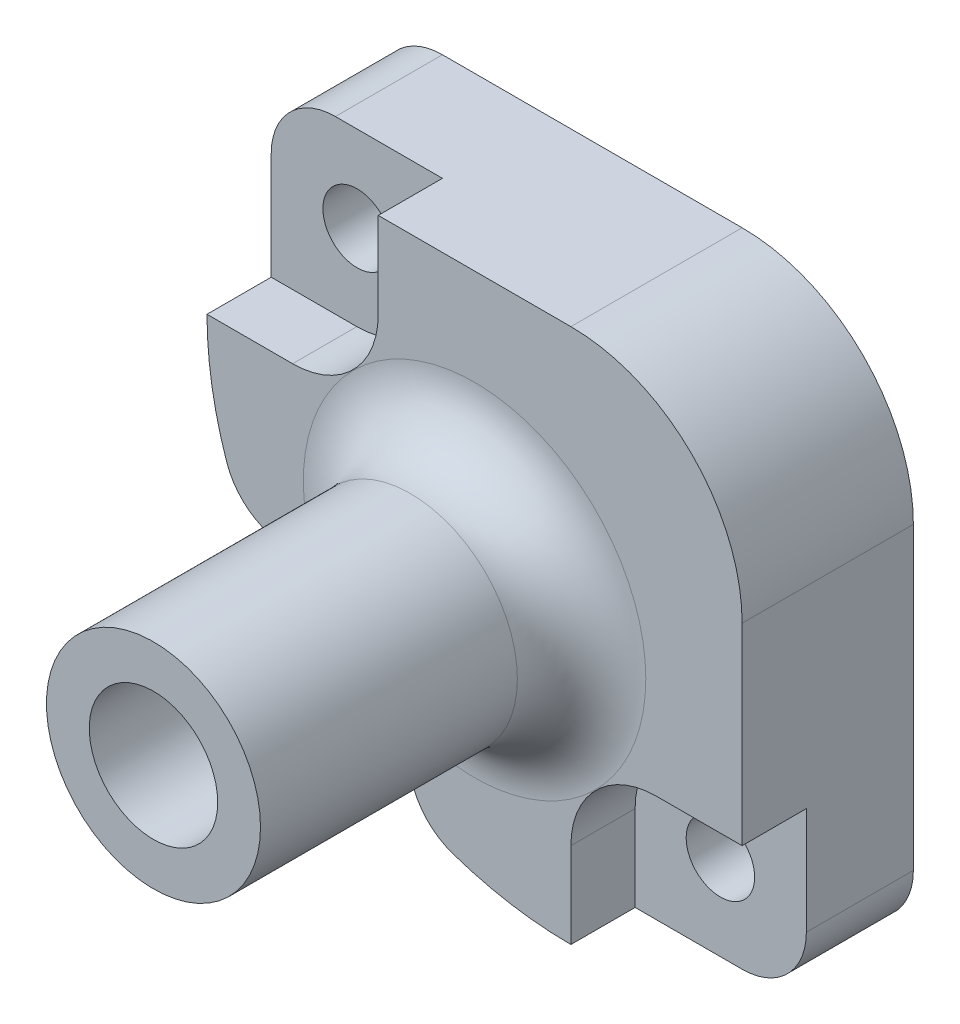
from build123d import *

# Parameters (mm, degrees)
SCHIZZO1_W                           = 25
SCHIZZO1_H                           = 25
ESTRUSIONE_ESTRUSIONE1_DEPTH         = 8
SCHIZZO8_R                           = 5
ESTRUSIONE_ESTRUSIONE3_DEPTH         = 15
RACCORDO1_R                          = 3
TAGLIO_ESTRUSIONE2_REACH             = 25
SCHIZZO9_R                           = 1.6
SCHIZZO10_R                          = 3
TAGLIO_ESTRUSIONE3_DEPTH             = 4
SCHIZZO11_R                          = 3
TAGLIO_ESTRUSIONE4_DEPTH             = 16
TAGLIO_ESTRUSIONE6_REACH             = 25
SCHIZZO13_R                          = 1.6
TAGLIO_ESTRUSIONE8_START             = -3
TAGLIO_ESTRUSIONE8_DEPTH             = 19
RIPETIZIONECIRCOLARE1_COUNT          = 2
RIPETIZIONECIRCOLARE1_ANGLE          = 180
TAGLIO_ESTRUSIONE9_REACH             = 10
TAGLIO_ESTRUSIONE9_DIRECTION_2_REACH = 17
RACCORDO2_R                          = 3
RACCORDO3_R                          = 3
RACCORDO4_R                          = 8


with BuildPart() as part:
    # Schizzo1 → Estrusione-Estrusione1 (new body)
    with BuildSketch(Plane.XY):
        Rectangle(SCHIZZO1_W, SCHIZZO1_H)
    extrude(amount=ESTRUSIONE_ESTRUSIONE1_DEPTH)

    # Schizzo8 → Estrusione-Estrusione3 (add)
    with BuildSketch(Plane.XY.offset(8)):
        Circle(SCHIZZO8_R)
    extrude(amount=ESTRUSIONE_ESTRUSIONE3_DEPTH)

    # Raccordo1
    raccordo1_edges = [part.edges().sort_by_distance(p)[0] for p in [
        (-5, 0, 8),
    ]]
    fillet(raccordo1_edges, radius=RACCORDO1_R)

    # Schizzo9 → Taglio-Estrusione2 (cut, up to next)
    with BuildSketch(Plane(origin=(0, 0, 0), x_dir=(-1, 0, 0), z_dir=(0, 0, -1)), mode=Mode.PRIVATE) as taglio_estrusione2_sk1:
        Circle(SCHIZZO9_R)
    taglio_estrusione2_tool1 = extrude(taglio_estrusione2_sk1.sketch, amount=-TAGLIO_ESTRUSIONE2_REACH, mode=Mode.PRIVATE) & part.part
    add(taglio_estrusione2_tool1.solids().sort_by_distance((0, 0, 0))[0], mode=Mode.SUBTRACT)

    # Schizzo10 → Taglio-Estrusione3 (cut)
    with BuildSketch(Plane(origin=(0, 0, 0), x_dir=(-1, 0, 0), z_dir=(0, 0, -1))):
        Circle(SCHIZZO10_R)
    extrude(amount=-TAGLIO_ESTRUSIONE3_DEPTH, mode=Mode.SUBTRACT)

    # Schizzo11 → Taglio-Estrusione4 (cut)
    with BuildSketch(Plane.XY.offset(23)):
        Circle(SCHIZZO11_R)
    extrude(amount=-TAGLIO_ESTRUSIONE4_DEPTH, mode=Mode.SUBTRACT)

    # Schizzo13 → Taglio-Estrusione6 (cut, up to next)
    with BuildSketch(Plane(origin=(0, 0, 0), x_dir=(-1, 0, 0), z_dir=(0, 0, -1)), mode=Mode.PRIVATE) as taglio_estrusione6_sk1:
        with Locations((-8.485281374, -8.485281374)):
            Circle(SCHIZZO13_R)
    taglio_estrusione6_tool1 = extrude(taglio_estrusione6_sk1.sketch, amount=-TAGLIO_ESTRUSIONE6_REACH, mode=Mode.PRIVATE) & part.part
    add(taglio_estrusione6_tool1.solids().sort_by_distance((8.485281, -8.485281, 0))[0], mode=Mode.SUBTRACT)
    # Schizzo13 → Taglio-Estrusione6 (cut, up to next)
    with BuildSketch(Plane(origin=(0, 0, 0), x_dir=(-1, 0, 0), z_dir=(0, 0, -1)), mode=Mode.PRIVATE) as taglio_estrusione6_sk2:
        with Locations((8.485281374, 8.485281374)):
            Circle(SCHIZZO13_R)
    taglio_estrusione6_tool2 = extrude(taglio_estrusione6_sk2.sketch, amount=-TAGLIO_ESTRUSIONE6_REACH, mode=Mode.PRIVATE) & part.part
    add(taglio_estrusione6_tool2.solids().sort_by_distance((-8.485281, 8.485281, 0))[0], mode=Mode.SUBTRACT)

    # Schizzo17 → Taglio-Estrusione8 (cut)
    with BuildSketch(Plane.XY.offset(8).offset(TAGLIO_ESTRUSIONE8_START)):
        with BuildLine():
            Line((4.5, -12.5), (4.5, -8.5))
            ThreePointArc((4.5, -8.5), (5.671572875, -5.671572875), (8.5, -4.5))
            Line((8.5, -4.5), (12.5, -4.5))
            Line((12.5, -4.5), (12.5, -12.5))
            Line((12.5, -12.5), (4.5, -12.5))
        make_face()
    taglio_estrusione8 = extrude(amount=TAGLIO_ESTRUSIONE8_DEPTH, mode=Mode.SUBTRACT)

    # RipetizioneCircolare1: Taglio-Estrusione8 ×2 about axis
    ripetizionecircolare1_axis = Axis((0, 0, 0), (0, 0, 1))
    for i in range(1, RIPETIZIONECIRCOLARE1_COUNT):
        add(taglio_estrusione8.rotate(ripetizionecircolare1_axis, i * RIPETIZIONECIRCOLARE1_ANGLE / (RIPETIZIONECIRCOLARE1_COUNT - 1)), mode=Mode.SUBTRACT)

    # Schizzo20 → Taglio-Estrusione9 (cut, up to next)
    with BuildSketch(Plane.XY.offset(8), mode=Mode.PRIVATE) as taglio_estrusione9_sk1:
        with BuildLine():
            Line((-12.5, -12.5), (4.5, -12.5))
            ThreePointArc((4.5, -12.5), (0.853575925, -12.104324481), (-2.623106886, -10.935716643))
            ThreePointArc((-2.623106886, -10.935716643), (-5.428932188, -5.428932188), (-10.935716643, -2.623106886))
            ThreePointArc((-10.935716643, -2.623106886), (-12.104324481, 0.853575925), (-12.5, 4.5))
            Line((-12.5, 4.5), (-12.5, -12.5))
        make_face()
    taglio_estrusione9_tool1 = extrude(taglio_estrusione9_sk1.sketch, amount=-TAGLIO_ESTRUSIONE9_REACH, mode=Mode.PRIVATE) & part.part
    add(taglio_estrusione9_tool1.solids().sort_by_distance((-8.104879, -8.104879, 8))[0], mode=Mode.SUBTRACT)

    # Schizzo20 → Taglio-Estrusione9 direction 2 (cut, up to next)
    with BuildSketch(Plane.XY.offset(8), mode=Mode.PRIVATE) as taglio_estrusione9_direction_2_sk1:
        with BuildLine():
            Line((-12.5, -12.5), (4.5, -12.5))
            ThreePointArc((4.5, -12.5), (0.853575925, -12.104324481), (-2.623106886, -10.935716643))
            ThreePointArc((-2.623106886, -10.935716643), (-5.428932188, -5.428932188), (-10.935716643, -2.623106886))
            ThreePointArc((-10.935716643, -2.623106886), (-12.104324481, 0.853575925), (-12.5, 4.5))
            Line((-12.5, 4.5), (-12.5, -12.5))
        make_face()
    taglio_estrusione9_direction_2_tool1 = extrude(taglio_estrusione9_direction_2_sk1.sketch, amount=TAGLIO_ESTRUSIONE9_DIRECTION_2_REACH, mode=Mode.PRIVATE) & part.part
    add(taglio_estrusione9_direction_2_tool1.solids().sort_by_distance((-8.104879, -8.104879, 8))[0], mode=Mode.SUBTRACT)

    # Raccordo2
    raccordo2_edges = [part.edges().sort_by_distance(p)[0] for p in [
        (-10.935716643, -2.623106886, 4),
        (-2.623106886, -10.935716643, 4),
    ]]
    fillet(raccordo2_edges, radius=RACCORDO2_R)

    # Raccordo3
    raccordo3_edges = [part.edges().sort_by_distance(p)[0] for p in [
        (12.5, -12.5, 2.5),
        (-12.5, 12.5, 2.5),
    ]]
    fillet(raccordo3_edges, radius=RACCORDO3_R)

    # Raccordo4
    raccordo4_edges = [part.edges().sort_by_distance(p)[0] for p in [
        (12.5, 12.5, 4),
    ]]
    fillet(raccordo4_edges, radius=RACCORDO4_R)


solid = part.part
